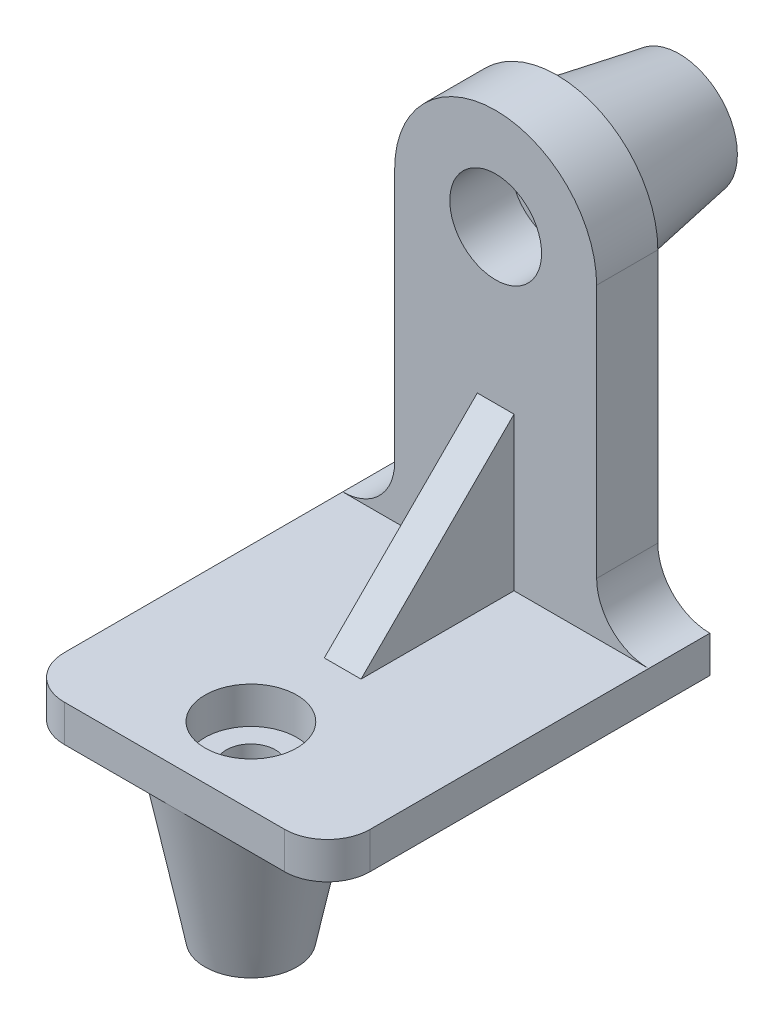
from build123d import *

# Parameters (mm, degrees)
CROQUIS1_R              = 15
SALIENTE_EXTRUIR1_DEPTH = 20
CROQUIS2_R              = 15
SALIENTE_EXTRUIR2_DEPTH = 12
SALIENTE_EXTRUIR3_DEPTH = 6


with BuildPart() as part:
    # Croquis1 → Saliente-Extruir1 (new body)
    with BuildSketch(Plane.XY):
        with BuildLine():
            Line((-50, 0), (50, 0))
            ThreePointArc((50, 0), (37.97918472, 4.97918472), (33, 17))
            Line((33, 17), (33, 100))
            ThreePointArc((33, 100), (0, 133), (-33, 100))
            Line((-33, 100), (-33, 17))
            ThreePointArc((-33, 17), (-37.97918472, 4.97918472), (-50, 0))
        make_face()
        with Locations((0, 100)):
            Circle(CROQUIS1_R, mode=Mode.SUBTRACT)
    extrude(amount=-SALIENTE_EXTRUIR1_DEPTH)

    # Croquis2 → Saliente-Extruir2 (add)
    with BuildSketch(Plane(origin=(0, 0, 0), x_dir=(1, 0, 0), z_dir=(0, 1, 0))):
        with BuildLine():
            Line((-50, 20), (-50, -91))
            ThreePointArc((-50, -91), (-45.899494937, -100.899494937), (-36, -105))
            Line((-36, -105), (36, -105))
            ThreePointArc((36, -105), (45.899494937, -100.899494937), (50, -91))
            Line((50, -91), (50, 20))
            Line((50, 20), (-50, 20))
        make_face()
        with Locations((0, -80)):
            Circle(CROQUIS2_R, mode=Mode.SUBTRACT)
    extrude(amount=-SALIENTE_EXTRUIR2_DEPTH)

    # Croquis3 → Saliente-Extruir3 (add, symmetric)
    with BuildSketch(Plane(origin=(0, 0, 0), x_dir=(0, 0, -1), z_dir=(1, 0, 0))):
        Polygon((0, 50), (-50, 0), (0, 0), align=None)
    extrude(amount=SALIENTE_EXTRUIR3_DEPTH, both=True)

    # Croquis5 → Revolución1 (revolve)
    with BuildSketch(Plane(origin=(0, 0, 0), x_dir=(0, 0, -1), z_dir=(1, 0, 0))):
        Polygon((20, 126), (60, 119), (60, 110), (20, 110), align=None)
    revolve(axis=Axis((0, 100, 0), (0, 0, -1)))

    # Croquis6 → Revolución2 (revolve)
    with BuildSketch(Plane(origin=(0, 0, 0), x_dir=(0, 0, -1), z_dir=(1, 0, 0))):
        Polygon((-105, -12), (-95, -62), (-88, -62), (-88, -12), align=None)
    revolve(axis=Axis((0, -12, 80), (0, -1, 0)))


solid = part.part
